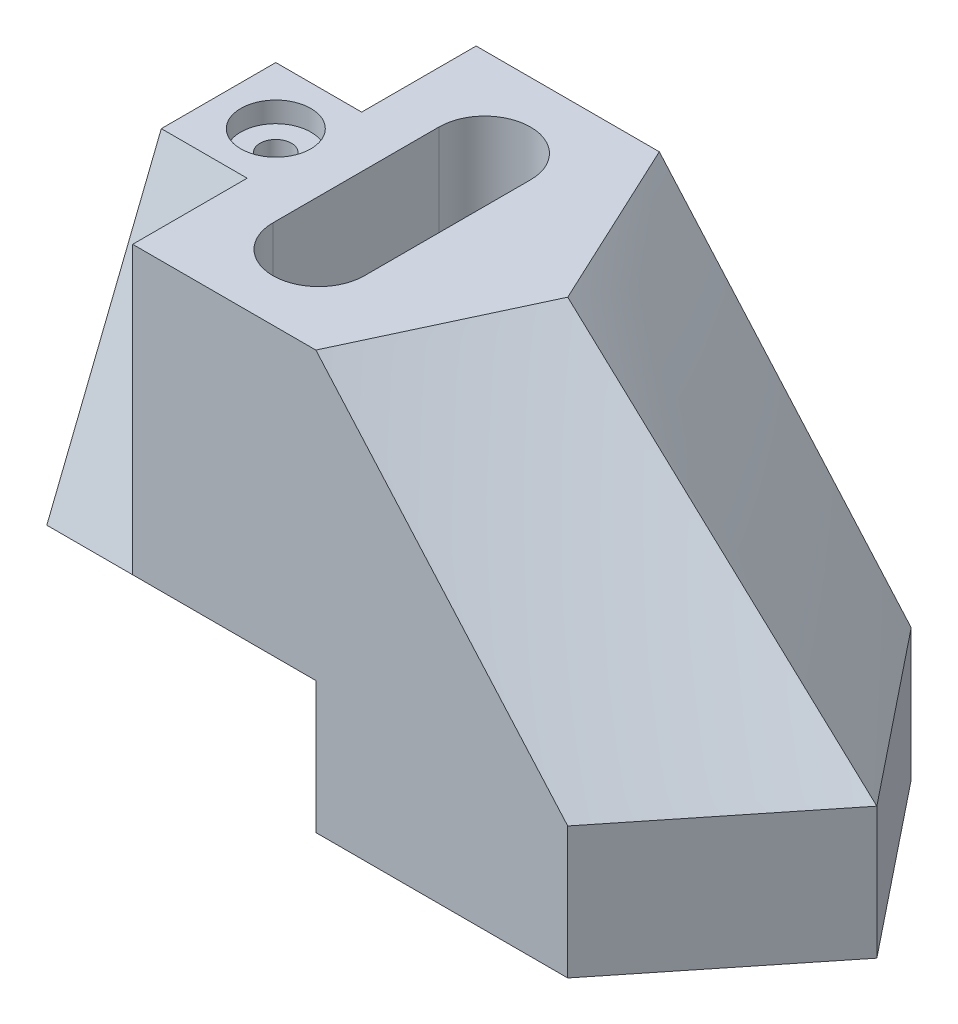
from build123d import *

# Parameters (mm, degrees)
BOSS_EXTRUDE2_DEPTH                     = 23
SKETCH17_W                              = 47
SKETCH17_H                              = 23
CUT_EXTRUDE5_DEPTH                      = 140.014387906
CUT_EXTRUDE6_DEPTH                      = 15
CUT_EXTRUDE7_DEPTH                      = 20
CUT_EXTRUDE8_DEPTH                      = 140.477596924
CBORE_FOR_M5_HEX_HEAD_BOLT2_D           = 5.5
CBORE_FOR_M5_HEX_HEAD_BOLT2_CBORE_D     = 12.24
CBORE_FOR_M5_HEX_HEAD_BOLT2_CBORE_DEPTH = 3.58


with BuildPart() as part:
    # Sketch15 → Loft2 section 0
    with BuildSketch(Plane(origin=(0, 50, 0), x_dir=(1, 0, 0), z_dir=(0, 1, 0))):
        with BuildLine():
            Line((0, 30), (0, -30))
            Line((0, -30), (47, -30))
            Line((47, -30), (61, 0))
            Line((61, 0), (47, 30))
            Line((47, 30), (0, 30))
        make_face()
    # Sketch1 → Loft2 section 1
    with BuildSketch(Plane(origin=(0, 0, 0), x_dir=(1, 0, 0), z_dir=(0, 1, 0))):
        with BuildLine():
            Line((0, -30), (0, 30))
            Line((0, 30), (91, 30))
            Line((91, 30), (115, 0))
            Line((115, 0), (91, -30))
            Line((91, -30), (0, -30))
        make_face()
    loft()

    # Sketch16 → Boss-Extrude2 (add)
    with BuildSketch(Plane.XZ):
        Polygon((91, 30), (0, 30), (0, -30), (91, -30), (115, 0), align=None)
    extrude(amount=BOSS_EXTRUDE2_DEPTH)

    # Sketch17 → Cut-Extrude5 (cut, through all)
    with BuildSketch(Plane.XY.offset(30)):
        with Locations((23.5, -11.5)):
            Rectangle(SKETCH17_W, SKETCH17_H)
    extrude(amount=-CUT_EXTRUDE5_DEPTH, mode=Mode.SUBTRACT)

    # Sketch19 → Cut-Extrude6 (cut)
    with BuildSketch(Plane.ZY):
        Polygon((10, 50), (30, 50), (30, 0), align=None)
        Polygon((-10, 50), (-30, 50), (-30, 0), align=None)
    extrude(amount=-CUT_EXTRUDE6_DEPTH, mode=Mode.SUBTRACT)

    # Sketch20 → Cut-Extrude7 (cut)
    with BuildSketch(Plane(origin=(0, 50, 0), x_dir=(1, 0, 0), z_dir=(0, 1, 0))):
        with BuildLine():
            Line((40, 14.5), (40, -14.5))
            ThreePointArc((40, -14.5), (32, -22.5), (24, -14.5))
            Line((24, -14.5), (24, 14.5))
            ThreePointArc((24, 14.5), (32, 22.5), (40, 14.5))
        make_face()
        with BuildLine():
            Line((35, 14.5), (35, -14.5))
            ThreePointArc((35, -14.5), (32, -17.5), (29, -14.5))
            Line((29, -14.5), (29, 14.5))
            ThreePointArc((29, 14.5), (32, 17.5), (35, 14.5))
        make_face(mode=Mode.SUBTRACT)
    extrude(amount=-CUT_EXTRUDE7_DEPTH, mode=Mode.SUBTRACT)

    # Sketch20_2 → Cut-Extrude8 (cut, through all)
    with BuildSketch(Plane(origin=(0, 50, 0), x_dir=(1, 0, 0), z_dir=(0, 1, 0))):
        with BuildLine():
            Line((35, -14.5), (35, 14.5))
            ThreePointArc((35, 14.5), (32, 17.5), (29, 14.5))
            Line((29, 14.5), (29, -14.5))
            ThreePointArc((29, -14.5), (32, -17.5), (35, -14.5))
        make_face()
    extrude(amount=-CUT_EXTRUDE8_DEPTH, mode=Mode.SUBTRACT)

    # CBORE for M5 Hex Head Bolt2 (through all)
    with Locations(Plane(origin=(0, 50, 0), x_dir=(1, 0, 0), z_dir=(0, 1, 0))):
        with Locations((10, 0)):
            CounterBoreHole(CBORE_FOR_M5_HEX_HEAD_BOLT2_D / 2, CBORE_FOR_M5_HEX_HEAD_BOLT2_CBORE_D / 2, CBORE_FOR_M5_HEX_HEAD_BOLT2_CBORE_DEPTH)


solid = part.part
